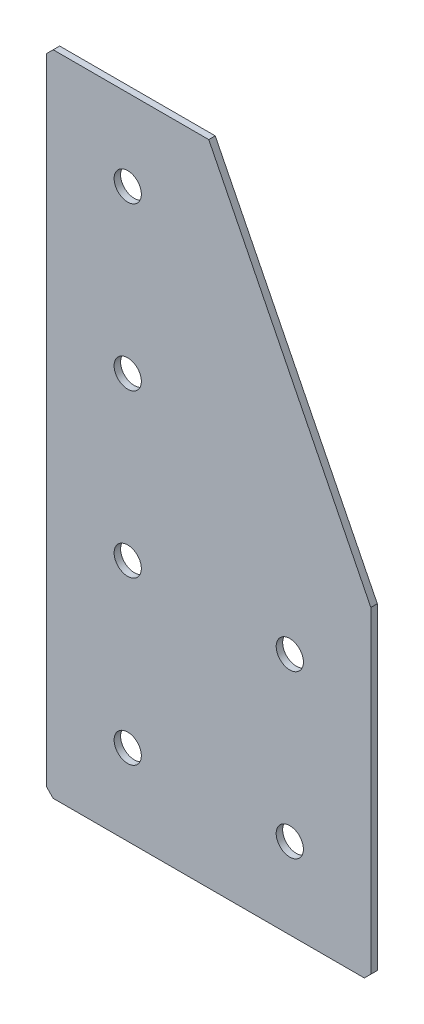
from build123d import *

# Parameters (mm, degrees)
EXTRUDE_1_DEPTH       = 2
HOLE_WIZARD_M81_D     = 8.4
HOLE_WIZARD_M81_DEPTH = 2
CHAMFER_1_SIZE        = 2


with BuildPart() as part:
    # Эскиз1 → Бобышка-Вытянуть1 (new body)
    with BuildSketch(Plane(origin=(0, 0, 0), x_dir=(1, 0, 0), z_dir=(0, 0, -1))):
        Polygon((0, 0), (0, 200), (100, 200), (100, 100), (50, 0), align=None)
    extrude(amount=EXTRUDE_1_DEPTH)

    # Отверстие с зазором M81
    with Locations(Plane(origin=(0, 0, -2), x_dir=(1, 0, 0), z_dir=(0, 0, -1))):
        with Locations((25, 175), (25, 125), (25, 75), (25, 25), (75, 175), (75, 125)):
            Hole(HOLE_WIZARD_M81_D / 2, depth=HOLE_WIZARD_M81_DEPTH)

    # Фаска1
    chamfer_1_edges = [part.edges().sort_by_distance(p)[0] for p in [
        (0, 0, -1),
        (0, -200, -1),
        (100, -200, -1),
    ]]
    chamfer(chamfer_1_edges, length=CHAMFER_1_SIZE)


solid = part.part
